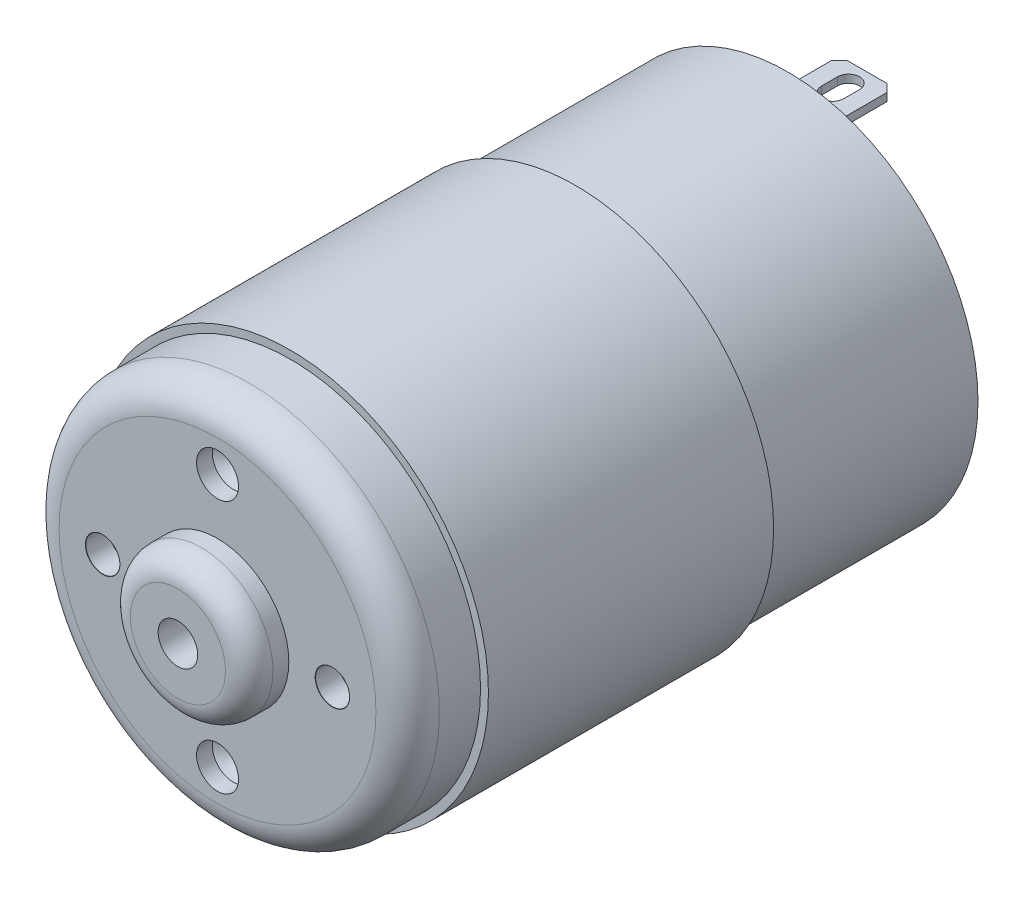
from build123d import *

# Parameters (mm, degrees)
SKETCH1_R                     = 24
BOSS_EXTRUDE1_DEPTH           = 72
SKETCH6_R                     = 9
BOSS_EXTRUDE2_DEPTH           = 5
SKETCH7_R                     = 9
BOSS_EXTRUDE3_DEPTH           = 5
SKETCH8_R                     = 2.5
CUT_EXTRUDE5_DEPTH            = 82
FILLET3_R                     = 3
FILLET4_R                     = 4
BOSS_EXTRUDE4_START           = -9.2
SKETCH9_R                     = 25
SKETCH9_R_2                   = 24
BOSS_EXTRUDE4_DEPTH           = 36
SKETCH10_W                    = 1
SKETCH10_H                    = 7
BOSS_EXTRUDE5_DEPTH           = 10
BOSS_EXTRUDE5_2_DEPTH         = 10
M4_CLEARANCE_HOLE5_AT_2_COUNT = 2
M4_CLEARANCE_HOLE5_AT_2_PITCH = 29
M5_CLEARANCE_HOLE1_AT_2_COUNT = 2
M5_CLEARANCE_HOLE1_AT_2_PITCH = 32
CUT_EXTRUDE7_DEPTH            = 1
CUT_EXTRUDE8_DEPTH            = 1


with BuildPart() as part:
    # Sketch1 → Boss-Extrude1 (new body)
    with BuildSketch(Plane(origin=(0, 0, 0), x_dir=(0, 1, 0), z_dir=(0, 0, 1))):
        Circle(SKETCH1_R)
    extrude(amount=BOSS_EXTRUDE1_DEPTH)

    # Sketch6 → Boss-Extrude2 (add)
    with BuildSketch(Plane.XY.offset(72)):
        Circle(SKETCH6_R)
    extrude(amount=BOSS_EXTRUDE2_DEPTH)

    # Sketch7 → Boss-Extrude3 (add)
    with BuildSketch(Plane(origin=(0, 0, 0), x_dir=(0, 1, 0), z_dir=(0, 0, 1))):
        Circle(SKETCH7_R)
    extrude(amount=-BOSS_EXTRUDE3_DEPTH)

    # Sketch8 → Cut-Extrude5 (cut)
    with BuildSketch(Plane.XY.offset(77)):
        Circle(SKETCH8_R)
    extrude(amount=-CUT_EXTRUDE5_DEPTH, mode=Mode.SUBTRACT)

    # Fillet3
    fillet3_edges = [part.edges().sort_by_distance(p)[0] for p in [
        (0, -9, -5),
        (-9, 0, 77),
    ]]
    fillet(fillet3_edges, radius=FILLET3_R)

    # Fillet4
    fillet4_edges = [part.edges().sort_by_distance(p)[0] for p in [
        (0, -24, 72),
    ]]
    fillet(fillet4_edges, radius=FILLET4_R)

    # Sketch9 → Boss-Extrude4 (add)
    with BuildSketch(Plane.XY.offset(72).offset(BOSS_EXTRUDE4_START)):
        Circle(SKETCH9_R)
        Circle(SKETCH9_R_2, mode=Mode.SUBTRACT)
    extrude(amount=-BOSS_EXTRUDE4_DEPTH)

    # Sketch18 → M4 Clearance Hole5 (revolve, cut)
    with BuildSketch(Plane(origin=(14.5, 0, 72), x_dir=(0, -1, 0), z_dir=(1, 0, 0))):
        Polygon((0, 0), (0, 4.291850331), (2.15, 3), (2.15, 0.025), (2.175, 0), align=None)
    m4_clearance_hole5 = revolve(axis=Axis((14.5, 0, 78.35), (0, 0, -1)), mode=Mode.SUBTRACT)

    # M4 Clearance Hole5 at 2: M4 Clearance Hole5 ×2
    with Locations(*[(-i * M4_CLEARANCE_HOLE5_AT_2_PITCH, 0, 0) for i in range(1, M4_CLEARANCE_HOLE5_AT_2_COUNT)]):
        add(m4_clearance_hole5, mode=Mode.SUBTRACT)

    # Sketch20 → M5 Clearance Hole1 (revolve, cut)
    with BuildSketch(Plane(origin=(0, 16, 77), x_dir=(0, -1, 0), z_dir=(1, 0, 0))):
        Polygon((0, 0), (0, 8.59228064), (2.65, 7), (2.65, 0.025), (2.675, 0), align=None)
    m5_clearance_hole1 = revolve(axis=Axis((0, 16, 83.35), (0, 0, -1)), mode=Mode.SUBTRACT)

    # M5 Clearance Hole1 at 2: M5 Clearance Hole1 ×2
    with Locations(*[(0, -i * M5_CLEARANCE_HOLE1_AT_2_PITCH, 0) for i in range(1, M5_CLEARANCE_HOLE1_AT_2_COUNT)]):
        add(m5_clearance_hole1, mode=Mode.SUBTRACT)


with BuildPart() as body_2:
    # Sketch10 → Boss-Extrude5 (new body)
    with BuildSketch(Plane(origin=(0, 0, 0), x_dir=(0, 1, 0), z_dir=(0, 0, 1))):
        with Locations((-18.5, 0)):
            Rectangle(SKETCH10_W, SKETCH10_H)
    extrude(amount=-BOSS_EXTRUDE5_DEPTH)

    # Sketch21 → Cut-Extrude7 (cut)
    with BuildSketch(Plane.XZ.offset(19)):
        Polygon((-3, -1.843628969), (-3, -0.016625164), (-3.5, 0), (-3.5, -2.3), align=None)
        Polygon((3.5, 0), (3, -0.016625164), (3, -1.8), (3.5, -2.3), align=None)
        Polygon((-2.587257938, -10), (-3.5, -9), (-3.5, -10), align=None)
        Polygon((3.5, -10), (3.5, -9), (2.5, -10), align=None)
        with BuildLine():
            Line((-1.394443017, -5.5), (-1.394443017, -7.5))
            ThreePointArc((-1.394443017, -7.5), (0, -8.894443017), (1.394443017, -7.5))
            Line((1.394443017, -7.5), (1.394443017, -5.5))
            ThreePointArc((1.394443017, -5.5), (0, -4.105556983), (-1.394443017, -5.5))
        make_face()
    extrude(amount=-CUT_EXTRUDE7_DEPTH, mode=Mode.SUBTRACT)


with BuildPart() as body_3:
    # Sketch10 → Boss-Extrude5 2 (new body)
    with BuildSketch(Plane(origin=(0, 0, 0), x_dir=(0, 1, 0), z_dir=(0, 0, 1))):
        with Locations((18.5, 0)):
            Rectangle(SKETCH10_W, SKETCH10_H)
    extrude(amount=-BOSS_EXTRUDE5_2_DEPTH)

    # Sketch23 → Cut-Extrude8 (cut)
    with BuildSketch(Plane(origin=(0, 19, 0), x_dir=(-1, 0, 0), z_dir=(0, 1, 0))):
        Polygon((-3, -1.843628969), (-3, -0.016625164), (-3.5, 0), (-3.5, -2.343628969), align=None)
        Polygon((3.5, 0), (3.025079896, -0.016625164), (3.025079896, -1.915500434), (3.5, -2.390420538), align=None)
        Polygon((-2.5, -10), (-3.5, -9), (-3.5, -10), align=None)
        Polygon((3.5, -10), (3.5, -9), (2.5, -10), align=None)
        with BuildLine():
            Line((-1.446794446, -5.605556983), (-1.446794446, -7.605556983))
            ThreePointArc((-1.446794446, -7.605556983), (-0.052351429, -9), (1.342091587, -7.605556983))
            Line((1.342091587, -7.605556983), (1.342091587, -5.605556983))
            ThreePointArc((1.342091587, -5.605556983), (-0.052351429, -4.211113967), (-1.446794446, -5.605556983))
        make_face()
    extrude(amount=-CUT_EXTRUDE8_DEPTH, mode=Mode.SUBTRACT)


solid = Compound([part.part, body_2.part, body_3.part])
